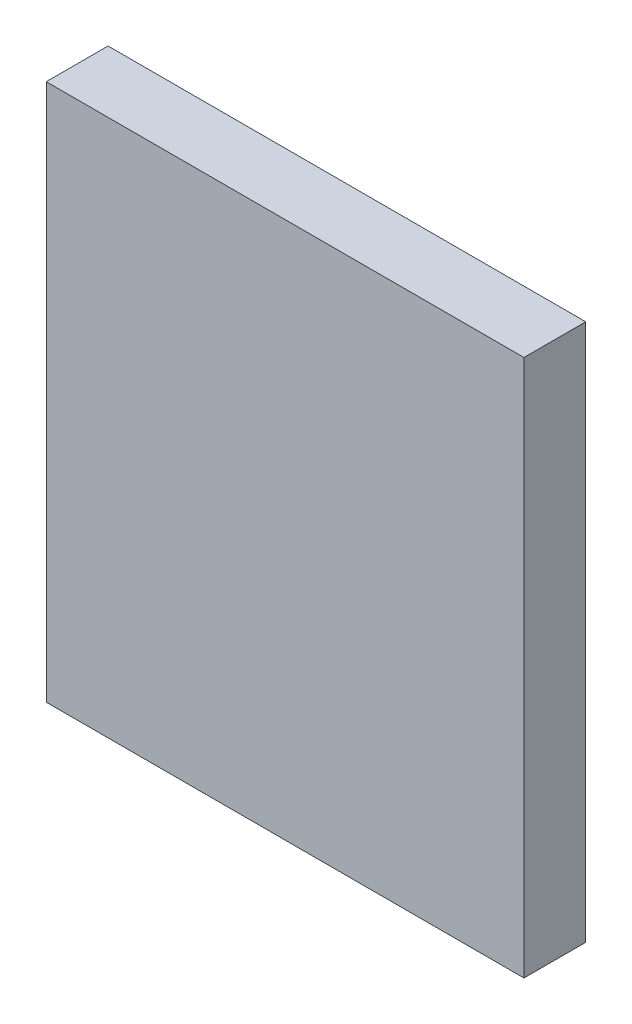
from build123d import *

# Parameters (mm, degrees)
SKETCH2_W           = 136
SKETCH2_H           = 153
BOSS_EXTRUDE1_DEPTH = 17.6


with BuildPart() as part:
    # Sketch2 → Boss-Extrude1 (new body)
    with BuildSketch(Plane.XY):
        with Locations((68, 76.5)):
            Rectangle(SKETCH2_W, SKETCH2_H)
    extrude(amount=BOSS_EXTRUDE1_DEPTH)


solid = part.part
